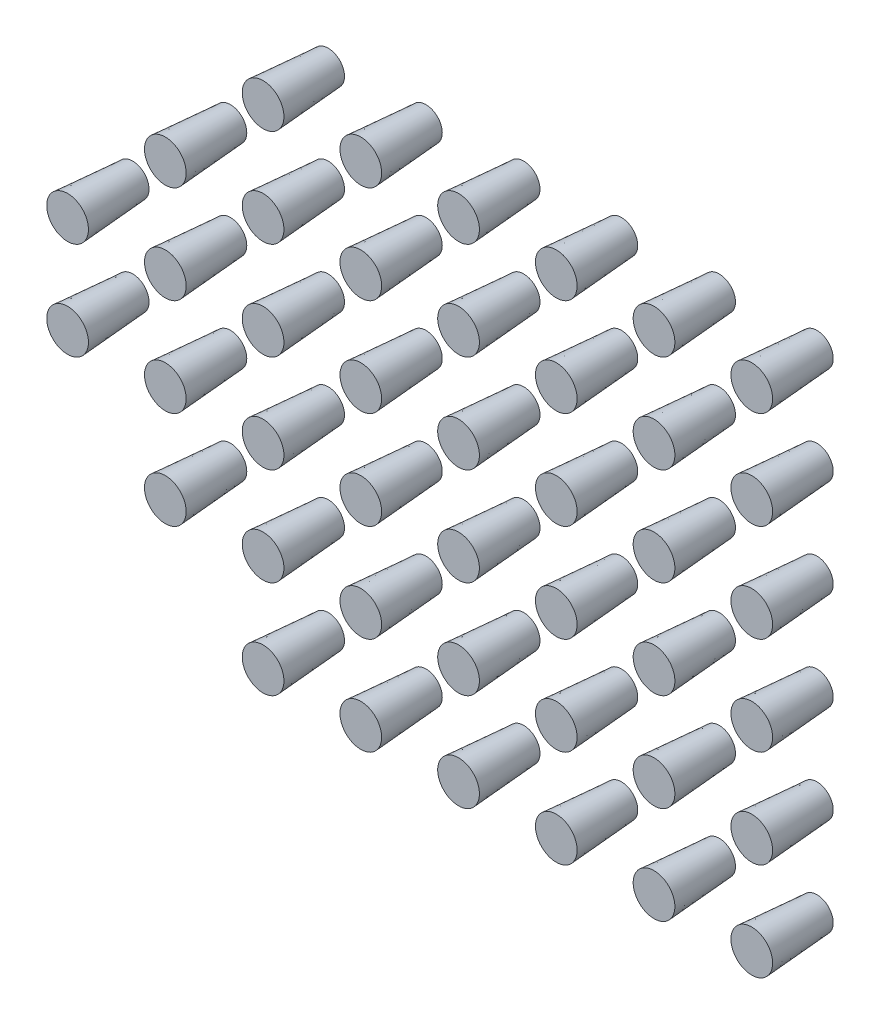
from build123d import *

# Parameters (mm, degrees)
SKETCH_1_R               = 0.5
EXTRUDE_1_DEPTH          = 2
EXTRUDE_1_TAPER          = -4
PATTERN_LINEAR_1_COUNT   = 6
PATTERN_LINEAR_1_PITCH   = 3
PATTERN_LINEAR_1_2_COUNT = 6
PATTERN_LINEAR_1_2_PITCH = 3
PATTERN_LINEAR_2_COUNT   = 2
PATTERN_LINEAR_2_PITCH   = 3
PATTERN_LINEAR_3_COUNT   = 2
PATTERN_LINEAR_3_PITCH   = 3


with BuildPart() as part:
    # 草图1 → 凸台-拉伸1 (new body)
    with BuildSketch(Plane.XY):
        Circle(SKETCH_1_R)
    extrude(amount=EXTRUDE_1_DEPTH, taper=EXTRUDE_1_TAPER)


with BuildPart() as pattern_linear_1_1:
    # 阵列(线性)1: pattern copy
    add(part.part.moved(Location(Vector(0, 1, 0) * (1 * PATTERN_LINEAR_1_PITCH))))


with BuildPart() as pattern_linear_1_2:
    # 阵列(线性)1: pattern copy
    add(part.part.moved(Location(Vector(0, 1, 0) * (2 * PATTERN_LINEAR_1_PITCH))))


with BuildPart() as pattern_linear_1_3:
    # 阵列(线性)1: pattern copy
    add(part.part.moved(Location(Vector(0, 1, 0) * (3 * PATTERN_LINEAR_1_PITCH))))


with BuildPart() as pattern_linear_1_4:
    # 阵列(线性)1: pattern copy
    add(part.part.moved(Location(Vector(0, 1, 0) * (4 * PATTERN_LINEAR_1_PITCH))))


with BuildPart() as pattern_linear_1_5:
    # 阵列(线性)1: pattern copy
    add(part.part.moved(Location(Vector(0, 1, 0) * (5 * PATTERN_LINEAR_1_PITCH))))


with BuildPart() as pattern_linear_1_2_1:
    # Pattern Linear 1 2: pattern copy
    add(part.part.moved(Location(Vector(1, 0, 0) * (1 * PATTERN_LINEAR_1_2_PITCH))))


with BuildPart() as pattern_linear_1_2_2:
    # Pattern Linear 1 2: pattern copy
    add(part.part.moved(Location(Vector(1, 0, 0) * (2 * PATTERN_LINEAR_1_2_PITCH))))


with BuildPart() as pattern_linear_1_2_3:
    # Pattern Linear 1 2: pattern copy
    add(part.part.moved(Location(Vector(1, 0, 0) * (3 * PATTERN_LINEAR_1_2_PITCH))))


with BuildPart() as pattern_linear_1_2_4:
    # Pattern Linear 1 2: pattern copy
    add(part.part.moved(Location(Vector(1, 0, 0) * (4 * PATTERN_LINEAR_1_2_PITCH))))


with BuildPart() as pattern_linear_1_2_5:
    # Pattern Linear 1 2: pattern copy
    add(part.part.moved(Location(Vector(1, 0, 0) * (5 * PATTERN_LINEAR_1_2_PITCH))))


with BuildPart() as pattern_linear_1_2_6:
    # Pattern Linear 1 2: pattern copy
    add(pattern_linear_1_1.part.moved(Location(Vector(1, 0, 0) * (1 * PATTERN_LINEAR_1_2_PITCH))))


with BuildPart() as pattern_linear_1_2_7:
    # Pattern Linear 1 2: pattern copy
    add(pattern_linear_1_1.part.moved(Location(Vector(1, 0, 0) * (2 * PATTERN_LINEAR_1_2_PITCH))))


with BuildPart() as pattern_linear_1_2_8:
    # Pattern Linear 1 2: pattern copy
    add(pattern_linear_1_1.part.moved(Location(Vector(1, 0, 0) * (3 * PATTERN_LINEAR_1_2_PITCH))))


with BuildPart() as pattern_linear_1_2_9:
    # Pattern Linear 1 2: pattern copy
    add(pattern_linear_1_1.part.moved(Location(Vector(1, 0, 0) * (4 * PATTERN_LINEAR_1_2_PITCH))))


with BuildPart() as pattern_linear_1_2_10:
    # Pattern Linear 1 2: pattern copy
    add(pattern_linear_1_1.part.moved(Location(Vector(1, 0, 0) * (5 * PATTERN_LINEAR_1_2_PITCH))))


with BuildPart() as pattern_linear_1_2_11:
    # Pattern Linear 1 2: pattern copy
    add(pattern_linear_1_2.part.moved(Location(Vector(1, 0, 0) * (1 * PATTERN_LINEAR_1_2_PITCH))))


with BuildPart() as pattern_linear_1_2_12:
    # Pattern Linear 1 2: pattern copy
    add(pattern_linear_1_2.part.moved(Location(Vector(1, 0, 0) * (2 * PATTERN_LINEAR_1_2_PITCH))))


with BuildPart() as pattern_linear_1_2_13:
    # Pattern Linear 1 2: pattern copy
    add(pattern_linear_1_2.part.moved(Location(Vector(1, 0, 0) * (3 * PATTERN_LINEAR_1_2_PITCH))))


with BuildPart() as pattern_linear_1_2_14:
    # Pattern Linear 1 2: pattern copy
    add(pattern_linear_1_2.part.moved(Location(Vector(1, 0, 0) * (4 * PATTERN_LINEAR_1_2_PITCH))))


with BuildPart() as pattern_linear_1_2_15:
    # Pattern Linear 1 2: pattern copy
    add(pattern_linear_1_2.part.moved(Location(Vector(1, 0, 0) * (5 * PATTERN_LINEAR_1_2_PITCH))))


with BuildPart() as pattern_linear_1_2_16:
    # Pattern Linear 1 2: pattern copy
    add(pattern_linear_1_3.part.moved(Location(Vector(1, 0, 0) * (1 * PATTERN_LINEAR_1_2_PITCH))))


with BuildPart() as pattern_linear_1_2_17:
    # Pattern Linear 1 2: pattern copy
    add(pattern_linear_1_3.part.moved(Location(Vector(1, 0, 0) * (2 * PATTERN_LINEAR_1_2_PITCH))))


with BuildPart() as pattern_linear_1_2_18:
    # Pattern Linear 1 2: pattern copy
    add(pattern_linear_1_3.part.moved(Location(Vector(1, 0, 0) * (3 * PATTERN_LINEAR_1_2_PITCH))))


with BuildPart() as pattern_linear_1_2_19:
    # Pattern Linear 1 2: pattern copy
    add(pattern_linear_1_3.part.moved(Location(Vector(1, 0, 0) * (4 * PATTERN_LINEAR_1_2_PITCH))))


with BuildPart() as pattern_linear_1_2_20:
    # Pattern Linear 1 2: pattern copy
    add(pattern_linear_1_3.part.moved(Location(Vector(1, 0, 0) * (5 * PATTERN_LINEAR_1_2_PITCH))))


with BuildPart() as pattern_linear_1_2_21:
    # Pattern Linear 1 2: pattern copy
    add(pattern_linear_1_4.part.moved(Location(Vector(1, 0, 0) * (1 * PATTERN_LINEAR_1_2_PITCH))))


with BuildPart() as pattern_linear_1_2_22:
    # Pattern Linear 1 2: pattern copy
    add(pattern_linear_1_4.part.moved(Location(Vector(1, 0, 0) * (2 * PATTERN_LINEAR_1_2_PITCH))))


with BuildPart() as pattern_linear_1_2_23:
    # Pattern Linear 1 2: pattern copy
    add(pattern_linear_1_4.part.moved(Location(Vector(1, 0, 0) * (3 * PATTERN_LINEAR_1_2_PITCH))))


with BuildPart() as pattern_linear_1_2_24:
    # Pattern Linear 1 2: pattern copy
    add(pattern_linear_1_4.part.moved(Location(Vector(1, 0, 0) * (4 * PATTERN_LINEAR_1_2_PITCH))))


with BuildPart() as pattern_linear_1_2_25:
    # Pattern Linear 1 2: pattern copy
    add(pattern_linear_1_4.part.moved(Location(Vector(1, 0, 0) * (5 * PATTERN_LINEAR_1_2_PITCH))))


with BuildPart() as pattern_linear_1_2_26:
    # Pattern Linear 1 2: pattern copy
    add(pattern_linear_1_5.part.moved(Location(Vector(1, 0, 0) * (1 * PATTERN_LINEAR_1_2_PITCH))))


with BuildPart() as pattern_linear_1_2_27:
    # Pattern Linear 1 2: pattern copy
    add(pattern_linear_1_5.part.moved(Location(Vector(1, 0, 0) * (2 * PATTERN_LINEAR_1_2_PITCH))))


with BuildPart() as pattern_linear_1_2_28:
    # Pattern Linear 1 2: pattern copy
    add(pattern_linear_1_5.part.moved(Location(Vector(1, 0, 0) * (3 * PATTERN_LINEAR_1_2_PITCH))))


with BuildPart() as pattern_linear_1_2_29:
    # Pattern Linear 1 2: pattern copy
    add(pattern_linear_1_5.part.moved(Location(Vector(1, 0, 0) * (4 * PATTERN_LINEAR_1_2_PITCH))))


with BuildPart() as pattern_linear_1_2_30:
    # Pattern Linear 1 2: pattern copy
    add(pattern_linear_1_5.part.moved(Location(Vector(1, 0, 0) * (5 * PATTERN_LINEAR_1_2_PITCH))))


with BuildPart() as pattern_linear_2_1:
    # 阵列(线性)2: pattern copy
    add(pattern_linear_1_4.part.moved(Location(Vector(-1, 0, 0) * (1 * PATTERN_LINEAR_2_PITCH))))


with BuildPart() as pattern_linear_2_2:
    # 阵列(线性)2: pattern copy
    add(pattern_linear_1_3.part.moved(Location(Vector(-1, 0, 0) * (1 * PATTERN_LINEAR_2_PITCH))))


with BuildPart() as pattern_linear_2_3:
    # 阵列(线性)2: pattern copy
    add(pattern_linear_1_2.part.moved(Location(Vector(-1, 0, 0) * (1 * PATTERN_LINEAR_2_PITCH))))


with BuildPart() as pattern_linear_2_4:
    # 阵列(线性)2: pattern copy
    add(pattern_linear_1_1.part.moved(Location(Vector(-1, 0, 0) * (1 * PATTERN_LINEAR_2_PITCH))))


with BuildPart() as pattern_linear_3_1:
    # 阵列(线性)3: pattern copy
    add(pattern_linear_2_2.part.moved(Location(Vector(-1, 0, 0) * (1 * PATTERN_LINEAR_3_PITCH))))


with BuildPart() as pattern_linear_3_2:
    # 阵列(线性)3: pattern copy
    add(pattern_linear_2_3.part.moved(Location(Vector(-1, 0, 0) * (1 * PATTERN_LINEAR_3_PITCH))))


solid = Compound([part.part, pattern_linear_1_1.part, pattern_linear_1_2.part, pattern_linear_1_3.part, pattern_linear_1_4.part, pattern_linear_1_5.part, pattern_linear_1_2_1.part, pattern_linear_1_2_2.part, pattern_linear_1_2_3.part, pattern_linear_1_2_4.part, pattern_linear_1_2_5.part, pattern_linear_1_2_6.part, pattern_linear_1_2_7.part, pattern_linear_1_2_8.part, pattern_linear_1_2_9.part, pattern_linear_1_2_10.part, pattern_linear_1_2_11.part, pattern_linear_1_2_12.part, pattern_linear_1_2_13.part, pattern_linear_1_2_14.part, pattern_linear_1_2_15.part, pattern_linear_1_2_16.part, pattern_linear_1_2_17.part, pattern_linear_1_2_18.part, pattern_linear_1_2_19.part, pattern_linear_1_2_20.part, pattern_linear_1_2_21.part, pattern_linear_1_2_22.part, pattern_linear_1_2_23.part, pattern_linear_1_2_24.part, pattern_linear_1_2_25.part, pattern_linear_1_2_26.part, pattern_linear_1_2_27.part, pattern_linear_1_2_28.part, pattern_linear_1_2_29.part, pattern_linear_1_2_30.part, pattern_linear_2_1.part, pattern_linear_2_2.part, pattern_linear_2_3.part, pattern_linear_2_4.part, pattern_linear_3_1.part, pattern_linear_3_2.part])
